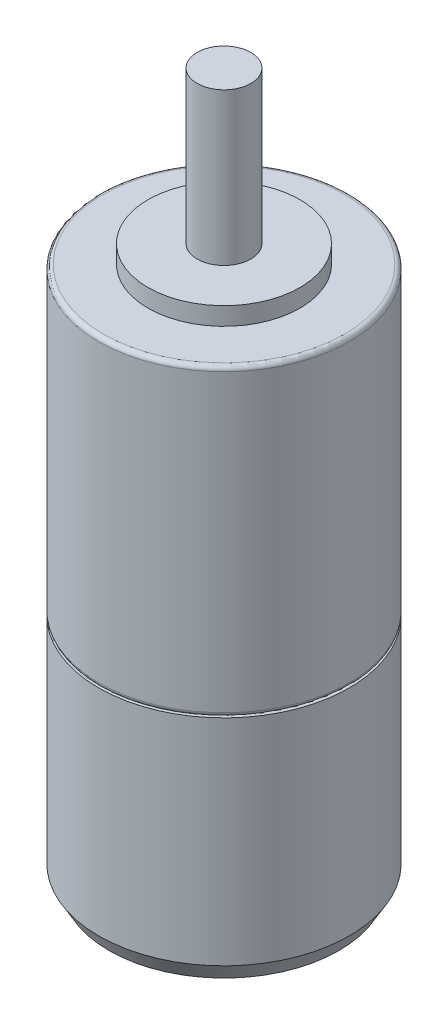
from build123d import *

# Parameters (mm, degrees)
SKETCH1_R           = 14
BOSS_EXTRUDE1_DEPTH = 34
SKETCH2_R           = 8.5
BOSS_EXTRUDE2_DEPTH = 2
SKETCH3_R           = 3
BOSS_EXTRUDE3_DEPTH = 17
FILLET1_R           = 0.5
SKETCH5_R           = 14
BOSS_EXTRUDE4_DEPTH = 26
CHAMFER1_SIZE       = 2
CHAMFER1_SIZE2      = 1.154700538
SKETCH6_R           = 6
CUT_EXTRUDE1_DEPTH  = 57


with BuildPart() as part:
    # Sketch1 → Boss-Extrude1 (new body)
    with BuildSketch(Plane(origin=(0, 0, 0), x_dir=(1, 0, 0), z_dir=(0, 1, 0))):
        Circle(SKETCH1_R)
    extrude(amount=BOSS_EXTRUDE1_DEPTH)

    # Sketch2 → Boss-Extrude2 (add)
    with BuildSketch(Plane(origin=(0, 34, 0), x_dir=(1, 0, 0), z_dir=(0, 1, 0))):
        Circle(SKETCH2_R)
    extrude(amount=BOSS_EXTRUDE2_DEPTH)

    # Sketch3 → Boss-Extrude3 (add)
    with BuildSketch(Plane(origin=(0, 36, 0), x_dir=(1, 0, 0), z_dir=(0, 1, 0))):
        Circle(SKETCH3_R)
    extrude(amount=BOSS_EXTRUDE3_DEPTH)

    # Fillet1
    fillet1_edges = [part.edges().sort_by_distance(p)[0] for p in [
        (-14, 0, 0),
        (-14, 34, 0),
    ]]
    fillet(fillet1_edges, radius=FILLET1_R)

    # Sketch5 → Boss-Extrude4 (add)
    with BuildSketch(Plane.XZ):
        Circle(SKETCH5_R)
    extrude(amount=BOSS_EXTRUDE4_DEPTH)

    # Chamfer1
    chamfer1_edges = [part.edges().sort_by_distance(p)[0] for p in [
        (-14, -26, 0),
    ]]
    chamfer1_side = [part.faces().sort_by_distance(p)[0] for p in [
        (-14, -13, 0),
    ]]
    chamfer(chamfer1_edges, length=CHAMFER1_SIZE, length2=CHAMFER1_SIZE2, reference=chamfer1_side[0])

    # Sketch6 → Cut-Extrude1 (cut)
    with BuildSketch(Plane.XZ.offset(26)):
        Circle(SKETCH6_R)
    extrude(amount=-CUT_EXTRUDE1_DEPTH, mode=Mode.SUBTRACT)


solid = part.part
